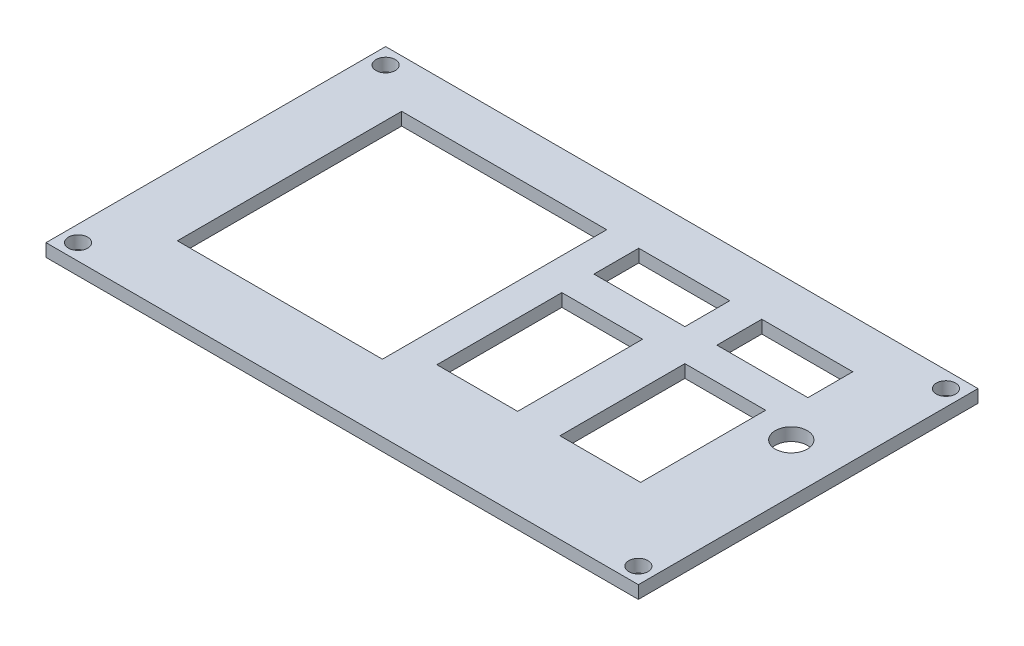
from build123d import *

# Parameters (mm, degrees)
SKETCH1_W           = 92.44
SKETCH1_H           = 53
BOSS_EXTRUDE1_DEPTH = 2
SKETCH2_R           = 1.5
CUT_EXTRUDE1_DEPTH  = 3
SKETCH3_R           = 2.5
SKETCH3_W           = 32
SKETCH3_H           = 35
SKETCH3_W_2         = 14.2
SKETCH3_H_2         = 7
SKETCH3_W_3         = 12.6
SKETCH3_H_3         = 19.5
CUT_EXTRUDE2_DEPTH  = 3


with BuildPart() as part:
    # Sketch1 → Boss-Extrude1 (new body)
    with BuildSketch(Plane(origin=(0, 0, 0), x_dir=(1, 0, 0), z_dir=(0, 1, 0))):
        Rectangle(SKETCH1_W, SKETCH1_H)
    extrude(amount=BOSS_EXTRUDE1_DEPTH)

    # Sketch2 → Cut-Extrude1 (cut, through all)
    with BuildSketch(Plane(origin=(0, 2, 0), x_dir=(1, 0, 0), z_dir=(0, 1, 0))):
        with Locations((-43.72, 24)):
            Circle(SKETCH2_R)
        with Locations((43.72, 24)):
            Circle(SKETCH2_R)
        with Locations((43.72, -24)):
            Circle(SKETCH2_R)
        with Locations((-43.72, -24)):
            Circle(SKETCH2_R)
    extrude(amount=-CUT_EXTRUDE1_DEPTH, mode=Mode.SUBTRACT)

    # Sketch3 → Cut-Extrude2 (cut, through all)
    with BuildSketch(Plane(origin=(0, 2, 0), x_dir=(1, 0, 0), z_dir=(0, 1, 0))):
        with Locations((38.58, 5)):
            Circle(SKETCH3_R)
        with Locations((-20.22, 1.5)):
            Rectangle(SKETCH3_W, SKETCH3_H)
        with Locations((7.88, 15.5)):
            Rectangle(SKETCH3_W_2, SKETCH3_H_2)
        with Locations((27.08, 15.5)):
            Rectangle(SKETCH3_W_2, SKETCH3_H_2)
        with Locations((7.08, -2.75)):
            Rectangle(SKETCH3_W_3, SKETCH3_H_3)
        with Locations((26.28, -2.75)):
            Rectangle(SKETCH3_W_3, SKETCH3_H_3)
    extrude(amount=-CUT_EXTRUDE2_DEPTH, mode=Mode.SUBTRACT)


solid = part.part
